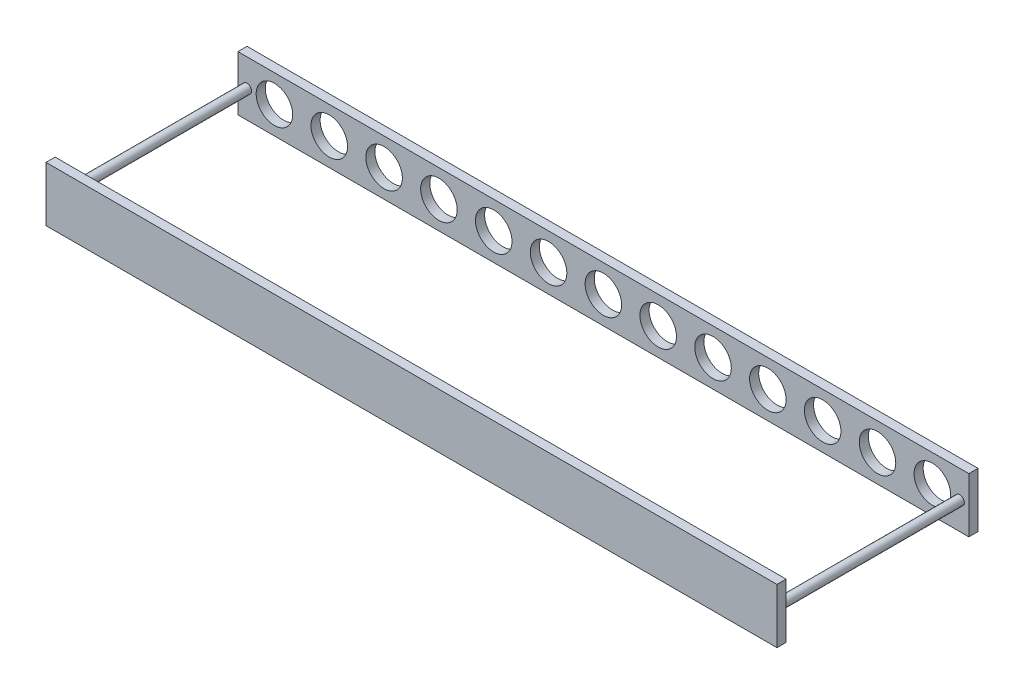
from build123d import *

# Parameters (mm, degrees)
SKETCH1_W                  = 800
SKETCH1_H                  = 60
BOSS_EXTRUDE1_DEPTH        = 10
SKETCH2_R                  = 20
CUT_EXTRUDE6_DEPTH         = 10
LPATTERN1_COUNT            = 7
LPATTERN1_PITCH            = 60
LPATTERN2_COPY_1_SKETCH_R  = 20
LPATTERN2_COPY_1_DEPTH     = 10
LPATTERN2_COPY_2_SKETCH_R  = 20
LPATTERN2_COPY_2_DEPTH     = 10
LPATTERN2_COPY_3_SKETCH_R  = 20
LPATTERN2_COPY_3_DEPTH     = 10
LPATTERN2_COPY_4_SKETCH_R  = 20
LPATTERN2_COPY_4_DEPTH     = 10
LPATTERN2_COPY_5_SKETCH_R  = 20
LPATTERN2_COPY_5_DEPTH     = 10
LPATTERN2_COPY_6_SKETCH_R  = 20
LPATTERN2_COPY_6_DEPTH     = 10
LPATTERN2_COPY_7_SKETCH_R  = 20
LPATTERN2_COPY_7_DEPTH     = 10
LPATTERN2_COPY_8_SKETCH_R  = 20
LPATTERN2_COPY_8_DEPTH     = 10
LPATTERN2_COPY_9_SKETCH_R  = 20
LPATTERN2_COPY_9_DEPTH     = 10
LPATTERN2_COPY_10_SKETCH_R = 20
LPATTERN2_COPY_10_DEPTH    = 10
LPATTERN2_COPY_11_SKETCH_R = 20
LPATTERN2_COPY_11_DEPTH    = 10
LPATTERN2_COPY_12_SKETCH_R = 20
LPATTERN2_COPY_12_DEPTH    = 10
LPATTERN2_COPY_13_SKETCH_R = 20
LPATTERN2_COPY_13_DEPTH    = 10
LPATTERN2_COPY_14_SKETCH_R = 20
LPATTERN2_COPY_14_DEPTH    = 10
LPATTERN2_COPY_15_SKETCH_R = 20
LPATTERN2_COPY_15_DEPTH    = 10
LPATTERN2_COPY_16_SKETCH_R = 20
LPATTERN2_COPY_16_DEPTH    = 10
LPATTERN2_COPY_17_SKETCH_R = 20
LPATTERN2_COPY_17_DEPTH    = 10
LPATTERN2_COPY_18_SKETCH_R = 20
LPATTERN2_COPY_18_DEPTH    = 10
LPATTERN2_COPY_19_SKETCH_R = 20
LPATTERN2_COPY_19_DEPTH    = 10
LPATTERN2_COPY_20_SKETCH_R = 20
LPATTERN2_COPY_20_DEPTH    = 10
LPATTERN2_COPY_21_SKETCH_R = 20
LPATTERN2_COPY_21_DEPTH    = 10
LPATTERN2_COPY_22_SKETCH_R = 20
LPATTERN2_COPY_22_DEPTH    = 10
LPATTERN2_COPY_23_SKETCH_R = 20
LPATTERN2_COPY_23_DEPTH    = 10
LPATTERN2_COPY_24_SKETCH_R = 20
LPATTERN2_COPY_24_DEPTH    = 10
LPATTERN2_COPY_25_SKETCH_R = 20
LPATTERN2_COPY_25_DEPTH    = 10
LPATTERN2_COPY_26_SKETCH_R = 20
LPATTERN2_COPY_26_DEPTH    = 10
LPATTERN2_COPY_27_SKETCH_R = 20
LPATTERN2_COPY_27_DEPTH    = 10
LPATTERN2_COPY_28_SKETCH_R = 20
LPATTERN2_COPY_28_DEPTH    = 10
LPATTERN2_COPY_29_SKETCH_R = 20
LPATTERN2_COPY_29_DEPTH    = 10
LPATTERN2_COPY_30_SKETCH_R = 20
LPATTERN2_COPY_30_DEPTH    = 10
LPATTERN2_COPY_31_SKETCH_R = 20
LPATTERN2_COPY_31_DEPTH    = 10
LPATTERN2_COPY_32_SKETCH_R = 20
LPATTERN2_COPY_32_DEPTH    = 10
LPATTERN2_COPY_33_SKETCH_R = 20
LPATTERN2_COPY_33_DEPTH    = 10
LPATTERN2_COPY_34_SKETCH_R = 20
LPATTERN2_COPY_34_DEPTH    = 10
LPATTERN2_COPY_35_SKETCH_R = 20
LPATTERN2_COPY_35_DEPTH    = 10
LPATTERN2_COPY_36_SKETCH_R = 20
LPATTERN2_COPY_36_DEPTH    = 10
LPATTERN2_COPY_37_SKETCH_R = 20
LPATTERN2_COPY_37_DEPTH    = 10
LPATTERN2_COPY_38_SKETCH_R = 20
LPATTERN2_COPY_38_DEPTH    = 10
LPATTERN2_COPY_39_SKETCH_R = 20
LPATTERN2_COPY_39_DEPTH    = 10
LPATTERN2_COPY_40_SKETCH_R = 20
LPATTERN2_COPY_40_DEPTH    = 10
LPATTERN2_COPY_41_SKETCH_R = 20
LPATTERN2_COPY_41_DEPTH    = 10
LPATTERN2_COPY_42_SKETCH_R = 20
LPATTERN2_COPY_42_DEPTH    = 10
SKETCH3_R                  = 5
BOSS_EXTRUDE2_DEPTH        = 200
SKETCH4_W                  = 800
SKETCH4_H                  = 60
BOSS_EXTRUDE3_DEPTH        = 10


with BuildPart() as part:
    # Sketch1 → Boss-Extrude1 (new body)
    with BuildSketch(Plane.XY):
        Rectangle(SKETCH1_W, SKETCH1_H)
    extrude(amount=BOSS_EXTRUDE1_DEPTH)

    # Sketch2 → Cut-Extrude6 (cut)
    with BuildSketch(Plane.XY):
        Circle(SKETCH2_R)
    cut_extrude6 = extrude(amount=CUT_EXTRUDE6_DEPTH, mode=Mode.SUBTRACT)

    # LPattern1: Cut-Extrude6 ×7
    with Locations(*[(i * LPATTERN1_PITCH, 0, 0) for i in range(1, LPATTERN1_COUNT)]):
        add(cut_extrude6, mode=Mode.SUBTRACT)

    # LPattern2 copy 1 sketch → LPattern2 copy 1 (cut)
    with BuildSketch(Plane.XY):
        Circle(LPATTERN2_COPY_1_SKETCH_R)
    extrude(amount=LPATTERN2_COPY_1_DEPTH, mode=Mode.SUBTRACT)

    # LPattern2 copy 2 sketch → LPattern2 copy 2 (cut)
    with BuildSketch(Plane(origin=(-60, 0, 0), x_dir=(1, 0, 0), z_dir=(0, 0, 1))):
        Circle(LPATTERN2_COPY_2_SKETCH_R)
    extrude(amount=LPATTERN2_COPY_2_DEPTH, mode=Mode.SUBTRACT)

    # LPattern2 copy 3 sketch → LPattern2 copy 3 (cut)
    with BuildSketch(Plane(origin=(-120, 0, 0), x_dir=(1, 0, 0), z_dir=(0, 0, 1))):
        Circle(LPATTERN2_COPY_3_SKETCH_R)
    extrude(amount=LPATTERN2_COPY_3_DEPTH, mode=Mode.SUBTRACT)

    # LPattern2 copy 4 sketch → LPattern2 copy 4 (cut)
    with BuildSketch(Plane(origin=(-180, 0, 0), x_dir=(1, 0, 0), z_dir=(0, 0, 1))):
        Circle(LPATTERN2_COPY_4_SKETCH_R)
    extrude(amount=LPATTERN2_COPY_4_DEPTH, mode=Mode.SUBTRACT)

    # LPattern2 copy 5 sketch → LPattern2 copy 5 (cut)
    with BuildSketch(Plane(origin=(-240, 0, 0), x_dir=(1, 0, 0), z_dir=(0, 0, 1))):
        Circle(LPATTERN2_COPY_5_SKETCH_R)
    extrude(amount=LPATTERN2_COPY_5_DEPTH, mode=Mode.SUBTRACT)

    # LPattern2 copy 6 sketch → LPattern2 copy 6 (cut)
    with BuildSketch(Plane(origin=(-300, 0, 0), x_dir=(1, 0, 0), z_dir=(0, 0, 1))):
        Circle(LPATTERN2_COPY_6_SKETCH_R)
    extrude(amount=LPATTERN2_COPY_6_DEPTH, mode=Mode.SUBTRACT)

    # LPattern2 copy 7 sketch → LPattern2 copy 7 (cut)
    with BuildSketch(Plane(origin=(60, 0, 0), x_dir=(1, 0, 0), z_dir=(0, 0, 1))):
        Circle(LPATTERN2_COPY_7_SKETCH_R)
    extrude(amount=LPATTERN2_COPY_7_DEPTH, mode=Mode.SUBTRACT)

    # LPattern2 copy 8 sketch → LPattern2 copy 8 (cut)
    with BuildSketch(Plane.XY):
        Circle(LPATTERN2_COPY_8_SKETCH_R)
    extrude(amount=LPATTERN2_COPY_8_DEPTH, mode=Mode.SUBTRACT)

    # LPattern2 copy 9 sketch → LPattern2 copy 9 (cut)
    with BuildSketch(Plane(origin=(-60, 0, 0), x_dir=(1, 0, 0), z_dir=(0, 0, 1))):
        Circle(LPATTERN2_COPY_9_SKETCH_R)
    extrude(amount=LPATTERN2_COPY_9_DEPTH, mode=Mode.SUBTRACT)

    # LPattern2 copy 10 sketch → LPattern2 copy 10 (cut)
    with BuildSketch(Plane(origin=(-120, 0, 0), x_dir=(1, 0, 0), z_dir=(0, 0, 1))):
        Circle(LPATTERN2_COPY_10_SKETCH_R)
    extrude(amount=LPATTERN2_COPY_10_DEPTH, mode=Mode.SUBTRACT)

    # LPattern2 copy 11 sketch → LPattern2 copy 11 (cut)
    with BuildSketch(Plane(origin=(-180, 0, 0), x_dir=(1, 0, 0), z_dir=(0, 0, 1))):
        Circle(LPATTERN2_COPY_11_SKETCH_R)
    extrude(amount=LPATTERN2_COPY_11_DEPTH, mode=Mode.SUBTRACT)

    # LPattern2 copy 12 sketch → LPattern2 copy 12 (cut)
    with BuildSketch(Plane(origin=(-240, 0, 0), x_dir=(1, 0, 0), z_dir=(0, 0, 1))):
        Circle(LPATTERN2_COPY_12_SKETCH_R)
    extrude(amount=LPATTERN2_COPY_12_DEPTH, mode=Mode.SUBTRACT)

    # LPattern2 copy 13 sketch → LPattern2 copy 13 (cut)
    with BuildSketch(Plane(origin=(120, 0, 0), x_dir=(1, 0, 0), z_dir=(0, 0, 1))):
        Circle(LPATTERN2_COPY_13_SKETCH_R)
    extrude(amount=LPATTERN2_COPY_13_DEPTH, mode=Mode.SUBTRACT)

    # LPattern2 copy 14 sketch → LPattern2 copy 14 (cut)
    with BuildSketch(Plane(origin=(60, 0, 0), x_dir=(1, 0, 0), z_dir=(0, 0, 1))):
        Circle(LPATTERN2_COPY_14_SKETCH_R)
    extrude(amount=LPATTERN2_COPY_14_DEPTH, mode=Mode.SUBTRACT)

    # LPattern2 copy 15 sketch → LPattern2 copy 15 (cut)
    with BuildSketch(Plane.XY):
        Circle(LPATTERN2_COPY_15_SKETCH_R)
    extrude(amount=LPATTERN2_COPY_15_DEPTH, mode=Mode.SUBTRACT)

    # LPattern2 copy 16 sketch → LPattern2 copy 16 (cut)
    with BuildSketch(Plane(origin=(-60, 0, 0), x_dir=(1, 0, 0), z_dir=(0, 0, 1))):
        Circle(LPATTERN2_COPY_16_SKETCH_R)
    extrude(amount=LPATTERN2_COPY_16_DEPTH, mode=Mode.SUBTRACT)

    # LPattern2 copy 17 sketch → LPattern2 copy 17 (cut)
    with BuildSketch(Plane(origin=(-120, 0, 0), x_dir=(1, 0, 0), z_dir=(0, 0, 1))):
        Circle(LPATTERN2_COPY_17_SKETCH_R)
    extrude(amount=LPATTERN2_COPY_17_DEPTH, mode=Mode.SUBTRACT)

    # LPattern2 copy 18 sketch → LPattern2 copy 18 (cut)
    with BuildSketch(Plane(origin=(-180, 0, 0), x_dir=(1, 0, 0), z_dir=(0, 0, 1))):
        Circle(LPATTERN2_COPY_18_SKETCH_R)
    extrude(amount=LPATTERN2_COPY_18_DEPTH, mode=Mode.SUBTRACT)

    # LPattern2 copy 19 sketch → LPattern2 copy 19 (cut)
    with BuildSketch(Plane(origin=(180, 0, 0), x_dir=(1, 0, 0), z_dir=(0, 0, 1))):
        Circle(LPATTERN2_COPY_19_SKETCH_R)
    extrude(amount=LPATTERN2_COPY_19_DEPTH, mode=Mode.SUBTRACT)

    # LPattern2 copy 20 sketch → LPattern2 copy 20 (cut)
    with BuildSketch(Plane(origin=(120, 0, 0), x_dir=(1, 0, 0), z_dir=(0, 0, 1))):
        Circle(LPATTERN2_COPY_20_SKETCH_R)
    extrude(amount=LPATTERN2_COPY_20_DEPTH, mode=Mode.SUBTRACT)

    # LPattern2 copy 21 sketch → LPattern2 copy 21 (cut)
    with BuildSketch(Plane(origin=(60, 0, 0), x_dir=(1, 0, 0), z_dir=(0, 0, 1))):
        Circle(LPATTERN2_COPY_21_SKETCH_R)
    extrude(amount=LPATTERN2_COPY_21_DEPTH, mode=Mode.SUBTRACT)

    # LPattern2 copy 22 sketch → LPattern2 copy 22 (cut)
    with BuildSketch(Plane.XY):
        Circle(LPATTERN2_COPY_22_SKETCH_R)
    extrude(amount=LPATTERN2_COPY_22_DEPTH, mode=Mode.SUBTRACT)

    # LPattern2 copy 23 sketch → LPattern2 copy 23 (cut)
    with BuildSketch(Plane(origin=(-60, 0, 0), x_dir=(1, 0, 0), z_dir=(0, 0, 1))):
        Circle(LPATTERN2_COPY_23_SKETCH_R)
    extrude(amount=LPATTERN2_COPY_23_DEPTH, mode=Mode.SUBTRACT)

    # LPattern2 copy 24 sketch → LPattern2 copy 24 (cut)
    with BuildSketch(Plane(origin=(-120, 0, 0), x_dir=(1, 0, 0), z_dir=(0, 0, 1))):
        Circle(LPATTERN2_COPY_24_SKETCH_R)
    extrude(amount=LPATTERN2_COPY_24_DEPTH, mode=Mode.SUBTRACT)

    # LPattern2 copy 25 sketch → LPattern2 copy 25 (cut)
    with BuildSketch(Plane(origin=(240, 0, 0), x_dir=(1, 0, 0), z_dir=(0, 0, 1))):
        Circle(LPATTERN2_COPY_25_SKETCH_R)
    extrude(amount=LPATTERN2_COPY_25_DEPTH, mode=Mode.SUBTRACT)

    # LPattern2 copy 26 sketch → LPattern2 copy 26 (cut)
    with BuildSketch(Plane(origin=(180, 0, 0), x_dir=(1, 0, 0), z_dir=(0, 0, 1))):
        Circle(LPATTERN2_COPY_26_SKETCH_R)
    extrude(amount=LPATTERN2_COPY_26_DEPTH, mode=Mode.SUBTRACT)

    # LPattern2 copy 27 sketch → LPattern2 copy 27 (cut)
    with BuildSketch(Plane(origin=(120, 0, 0), x_dir=(1, 0, 0), z_dir=(0, 0, 1))):
        Circle(LPATTERN2_COPY_27_SKETCH_R)
    extrude(amount=LPATTERN2_COPY_27_DEPTH, mode=Mode.SUBTRACT)

    # LPattern2 copy 28 sketch → LPattern2 copy 28 (cut)
    with BuildSketch(Plane(origin=(60, 0, 0), x_dir=(1, 0, 0), z_dir=(0, 0, 1))):
        Circle(LPATTERN2_COPY_28_SKETCH_R)
    extrude(amount=LPATTERN2_COPY_28_DEPTH, mode=Mode.SUBTRACT)

    # LPattern2 copy 29 sketch → LPattern2 copy 29 (cut)
    with BuildSketch(Plane.XY):
        Circle(LPATTERN2_COPY_29_SKETCH_R)
    extrude(amount=LPATTERN2_COPY_29_DEPTH, mode=Mode.SUBTRACT)

    # LPattern2 copy 30 sketch → LPattern2 copy 30 (cut)
    with BuildSketch(Plane(origin=(-60, 0, 0), x_dir=(1, 0, 0), z_dir=(0, 0, 1))):
        Circle(LPATTERN2_COPY_30_SKETCH_R)
    extrude(amount=LPATTERN2_COPY_30_DEPTH, mode=Mode.SUBTRACT)

    # LPattern2 copy 31 sketch → LPattern2 copy 31 (cut)
    with BuildSketch(Plane(origin=(300, 0, 0), x_dir=(1, 0, 0), z_dir=(0, 0, 1))):
        Circle(LPATTERN2_COPY_31_SKETCH_R)
    extrude(amount=LPATTERN2_COPY_31_DEPTH, mode=Mode.SUBTRACT)

    # LPattern2 copy 32 sketch → LPattern2 copy 32 (cut)
    with BuildSketch(Plane(origin=(240, 0, 0), x_dir=(1, 0, 0), z_dir=(0, 0, 1))):
        Circle(LPATTERN2_COPY_32_SKETCH_R)
    extrude(amount=LPATTERN2_COPY_32_DEPTH, mode=Mode.SUBTRACT)

    # LPattern2 copy 33 sketch → LPattern2 copy 33 (cut)
    with BuildSketch(Plane(origin=(180, 0, 0), x_dir=(1, 0, 0), z_dir=(0, 0, 1))):
        Circle(LPATTERN2_COPY_33_SKETCH_R)
    extrude(amount=LPATTERN2_COPY_33_DEPTH, mode=Mode.SUBTRACT)

    # LPattern2 copy 34 sketch → LPattern2 copy 34 (cut)
    with BuildSketch(Plane(origin=(120, 0, 0), x_dir=(1, 0, 0), z_dir=(0, 0, 1))):
        Circle(LPATTERN2_COPY_34_SKETCH_R)
    extrude(amount=LPATTERN2_COPY_34_DEPTH, mode=Mode.SUBTRACT)

    # LPattern2 copy 35 sketch → LPattern2 copy 35 (cut)
    with BuildSketch(Plane(origin=(60, 0, 0), x_dir=(1, 0, 0), z_dir=(0, 0, 1))):
        Circle(LPATTERN2_COPY_35_SKETCH_R)
    extrude(amount=LPATTERN2_COPY_35_DEPTH, mode=Mode.SUBTRACT)

    # LPattern2 copy 36 sketch → LPattern2 copy 36 (cut)
    with BuildSketch(Plane.XY):
        Circle(LPATTERN2_COPY_36_SKETCH_R)
    extrude(amount=LPATTERN2_COPY_36_DEPTH, mode=Mode.SUBTRACT)

    # LPattern2 copy 37 sketch → LPattern2 copy 37 (cut)
    with BuildSketch(Plane(origin=(-60, 0, 0), x_dir=(1, 0, 0), z_dir=(0, 0, 1))):
        Circle(LPATTERN2_COPY_37_SKETCH_R)
    extrude(amount=LPATTERN2_COPY_37_DEPTH, mode=Mode.SUBTRACT)

    # LPattern2 copy 38 sketch → LPattern2 copy 38 (cut)
    with BuildSketch(Plane(origin=(-120, 0, 0), x_dir=(1, 0, 0), z_dir=(0, 0, 1))):
        Circle(LPATTERN2_COPY_38_SKETCH_R)
    extrude(amount=LPATTERN2_COPY_38_DEPTH, mode=Mode.SUBTRACT)

    # LPattern2 copy 39 sketch → LPattern2 copy 39 (cut)
    with BuildSketch(Plane(origin=(-180, 0, 0), x_dir=(1, 0, 0), z_dir=(0, 0, 1))):
        Circle(LPATTERN2_COPY_39_SKETCH_R)
    extrude(amount=LPATTERN2_COPY_39_DEPTH, mode=Mode.SUBTRACT)

    # LPattern2 copy 40 sketch → LPattern2 copy 40 (cut)
    with BuildSketch(Plane(origin=(-240, 0, 0), x_dir=(1, 0, 0), z_dir=(0, 0, 1))):
        Circle(LPATTERN2_COPY_40_SKETCH_R)
    extrude(amount=LPATTERN2_COPY_40_DEPTH, mode=Mode.SUBTRACT)

    # LPattern2 copy 41 sketch → LPattern2 copy 41 (cut)
    with BuildSketch(Plane(origin=(-300, 0, 0), x_dir=(1, 0, 0), z_dir=(0, 0, 1))):
        Circle(LPATTERN2_COPY_41_SKETCH_R)
    extrude(amount=LPATTERN2_COPY_41_DEPTH, mode=Mode.SUBTRACT)

    # LPattern2 copy 42 sketch → LPattern2 copy 42 (cut)
    with BuildSketch(Plane(origin=(-360, 0, 0), x_dir=(1, 0, 0), z_dir=(0, 0, 1))):
        Circle(LPATTERN2_COPY_42_SKETCH_R)
    extrude(amount=LPATTERN2_COPY_42_DEPTH, mode=Mode.SUBTRACT)

    # Sketch3 → Boss-Extrude2 (add)
    with BuildSketch(Plane.XY.offset(10)):
        with Locations((-390, 0)):
            Circle(SKETCH3_R)
        with Locations((390, 0)):
            Circle(SKETCH3_R)
    extrude(amount=BOSS_EXTRUDE2_DEPTH)

    # Sketch4 → Boss-Extrude3 (add)
    with BuildSketch(Plane.XY.offset(210)):
        Rectangle(SKETCH4_W, SKETCH4_H)
    extrude(amount=BOSS_EXTRUDE3_DEPTH)


solid = part.part
